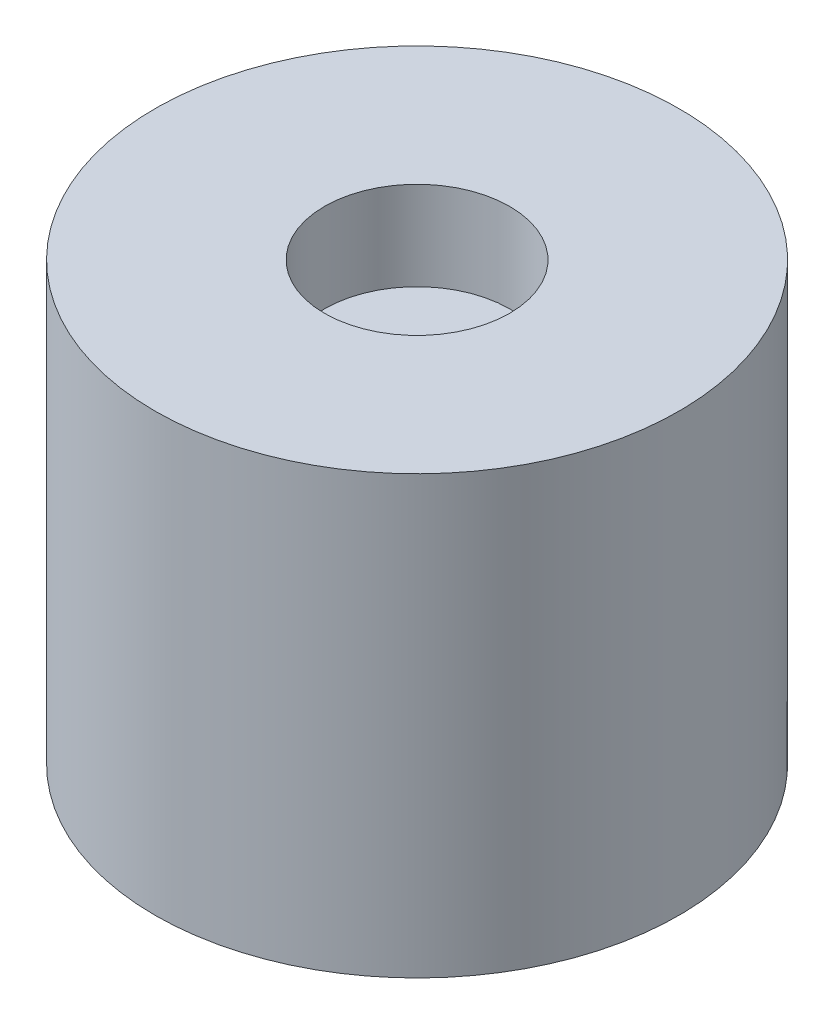
from build123d import *

# Parameters (mm, degrees)
SKETCH1_R           = 6
BOSS_EXTRUDE1_DEPTH = 10
SKETCH3_R           = 2.1209
CUT_EXTRUDE2_DEPTH  = 2.032
SKETCH2_R           = 4.05
CUT_EXTRUDE1_DEPTH  = 6.968


with BuildPart() as part:
    # Sketch1 → Boss-Extrude1 (new body)
    with BuildSketch(Plane(origin=(0, 0, 0), x_dir=(1, 0, 0), z_dir=(0, 1, 0))):
        Circle(SKETCH1_R)
    extrude(amount=BOSS_EXTRUDE1_DEPTH)

    # Sketch3 → Cut-Extrude2 (cut)
    with BuildSketch(Plane(origin=(0, 10, 0), x_dir=(1, 0, 0), z_dir=(0, 1, 0))):
        Circle(SKETCH3_R)
    extrude(amount=-CUT_EXTRUDE2_DEPTH, mode=Mode.SUBTRACT)

    # Sketch2 → Cut-Extrude1 (cut)
    with BuildSketch(Plane.XZ):
        Circle(SKETCH2_R)
    extrude(amount=-CUT_EXTRUDE1_DEPTH, mode=Mode.SUBTRACT)


solid = part.part
